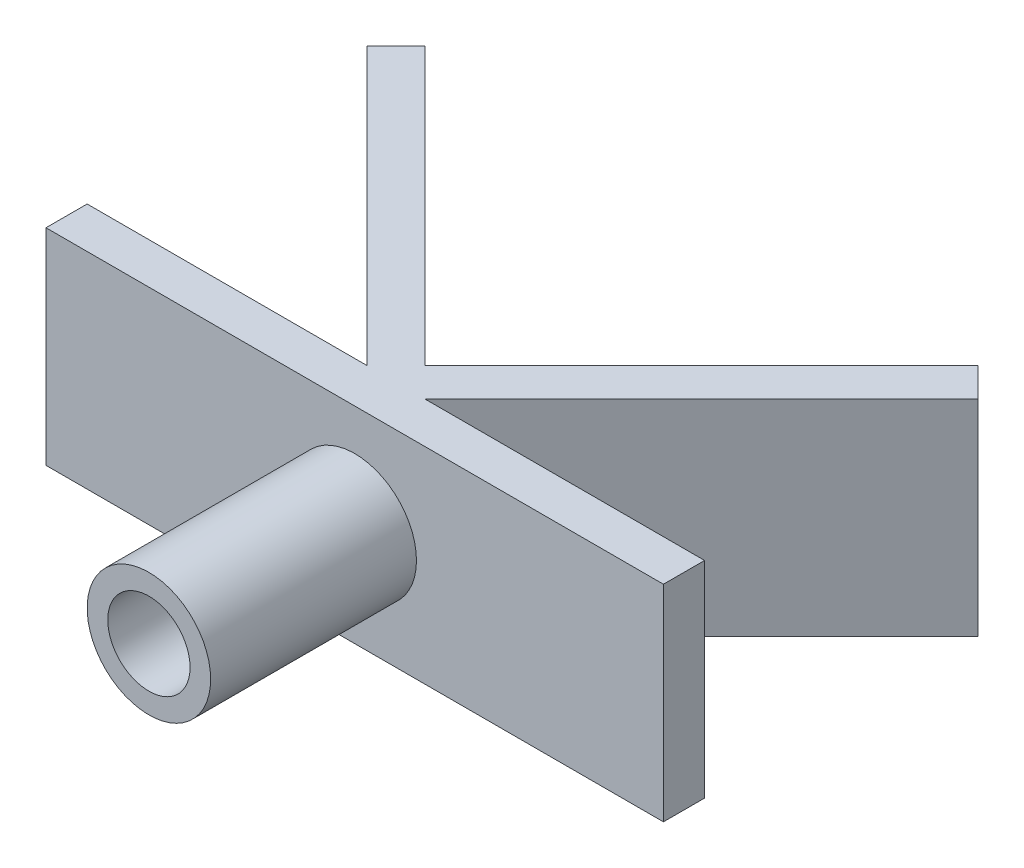
from build123d import *

# Parameters (mm, degrees)
SKETCH1_R           = 3
SKETCH1_R_2         = 2
BOSS_EXTRUDE1_DEPTH = 10
BOSS_EXTRUDE2_DEPTH = 2
BOSS_EXTRUDE3_DEPTH = 10


with BuildPart() as part:
    # Sketch1 → Boss-Extrude1 (new body)
    with BuildSketch(Plane.XY):
        Circle(SKETCH1_R)
        Circle(SKETCH1_R_2, mode=Mode.SUBTRACT)
    extrude(amount=BOSS_EXTRUDE1_DEPTH)

    # Sketch2 → Boss-Extrude2 (add)
    with BuildSketch(Plane(origin=(0, 0, 0), x_dir=(-1, 0, 0), z_dir=(0, 0, -1))):
        Polygon((0, -5), (15, -5), (15, 5), (-15, 5), (-15, -5), align=None)
    extrude(amount=BOSS_EXTRUDE2_DEPTH)

    # Sketch3 → Boss-Extrude3 (add)
    with BuildSketch(Plane(origin=(0, 5, 0), x_dir=(1, 0, 0), z_dir=(0, 1, 0))):
        Polygon((-0.707106781, 1.292893219), (0, 2), (0.707106781, 1.292893219), (14.849242405, 15.435028843), (13.435028843, 16.849242405), (0, 3.414213562), (-13.435028843, 16.849242405), (-14.849242405, 15.435028843), align=None)
    extrude(amount=-BOSS_EXTRUDE3_DEPTH)


solid = part.part
